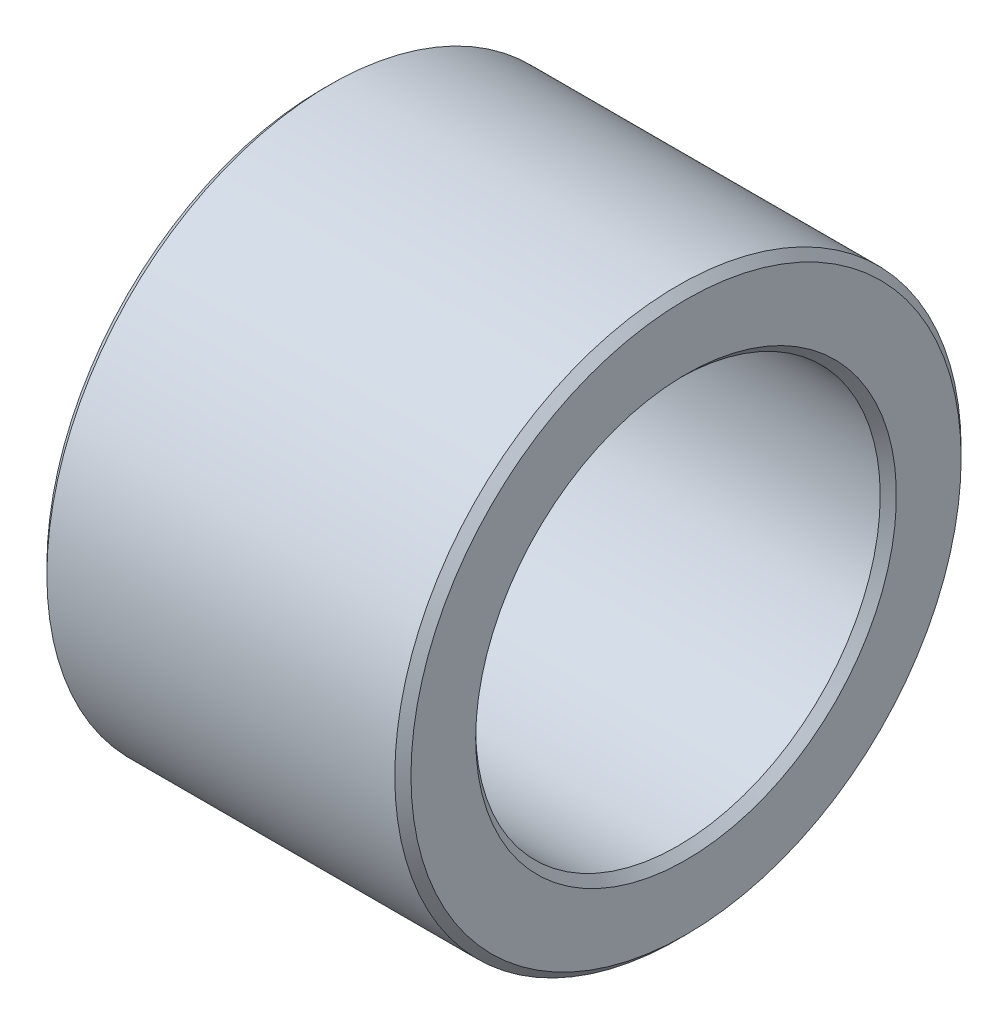
from build123d import *


with BuildPart() as part:
    # Эскиз1 → Повернуть1 (revolve)
    with BuildSketch(Plane.XY):
        Polygon((0.2, 5), (8.8, 5), (9, 5.2), (9, 6.8), (8.8, 7), (0.2, 7), (0, 6.8), (0, 5.2), align=None)
    revolve(axis=Axis((0, 0, 0), (1, 0, 0)))


solid = part.part
